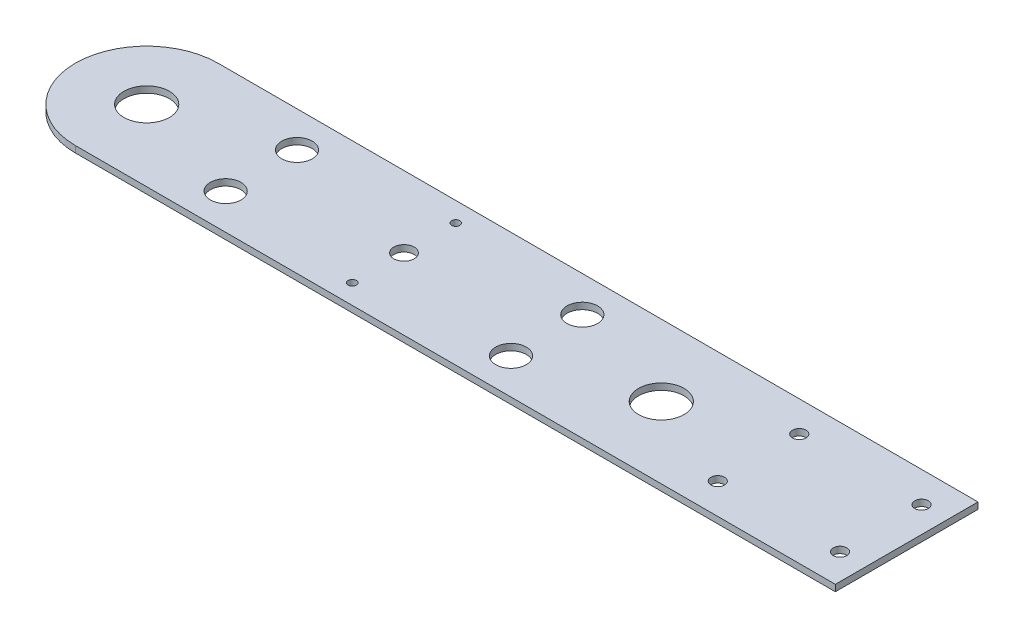
from build123d import *

# Parameters (mm, degrees)
SKETCH1_R           = 11.15
SKETCH1_R_2         = 7.5
SKETCH1_R_3         = 2.02
SKETCH1_R_4         = 3.325
BOSS_EXTRUDE1_DEPTH = 3.175


with BuildPart() as part:
    # Sketch1 → Boss-Extrude1 (new body)
    with BuildSketch(Plane(origin=(0, 0, 0), x_dir=(1, 0, 0), z_dir=(0, 1, 0))):
        with BuildLine():
            ThreePointArc((-126.258214395, 35), (-161.258214395, 0), (-126.258214395, -35))
            Line((-126.258214395, -35), (246.658214395, -35))
            Line((246.658214395, -35), (246.658214395, 35))
            Line((246.658214395, 35), (-126.258214395, 35))
        make_face()
        with Locations((-126.258214395, 0)):
            Circle(SKETCH1_R, mode=Mode.SUBTRACT)
        with Locations((-70, -17.5)):
            Circle(SKETCH1_R_2, mode=Mode.SUBTRACT)
        with Locations((0, -25.4)):
            Circle(SKETCH1_R_3, mode=Mode.SUBTRACT)
        with BuildLine():
            ThreePointArc((5, 0), (0, -5), (-5, 0))
            ThreePointArc((-5, 0), (0, 5), (5, 0))
        make_face(mode=Mode.SUBTRACT)
        with Locations((70, -17.5)):
            Circle(SKETCH1_R_2, mode=Mode.SUBTRACT)
        with Locations((173.958214395, -20)):
            Circle(SKETCH1_R_4, mode=Mode.SUBTRACT)
        with Locations((233.958214395, -20)):
            Circle(SKETCH1_R_4, mode=Mode.SUBTRACT)
        with Locations((-70, 17.5)):
            Circle(SKETCH1_R_2, mode=Mode.SUBTRACT)
        with Locations((0, 25.4)):
            Circle(SKETCH1_R_3, mode=Mode.SUBTRACT)
        with Locations((126.258214395, 0)):
            Circle(SKETCH1_R, mode=Mode.SUBTRACT)
        with Locations((70, 17.5)):
            Circle(SKETCH1_R_2, mode=Mode.SUBTRACT)
        with Locations((173.958214395, 20)):
            Circle(SKETCH1_R_4, mode=Mode.SUBTRACT)
        with Locations((233.958214395, 20)):
            Circle(SKETCH1_R_4, mode=Mode.SUBTRACT)
    extrude(amount=BOSS_EXTRUDE1_DEPTH)


solid = part.part
